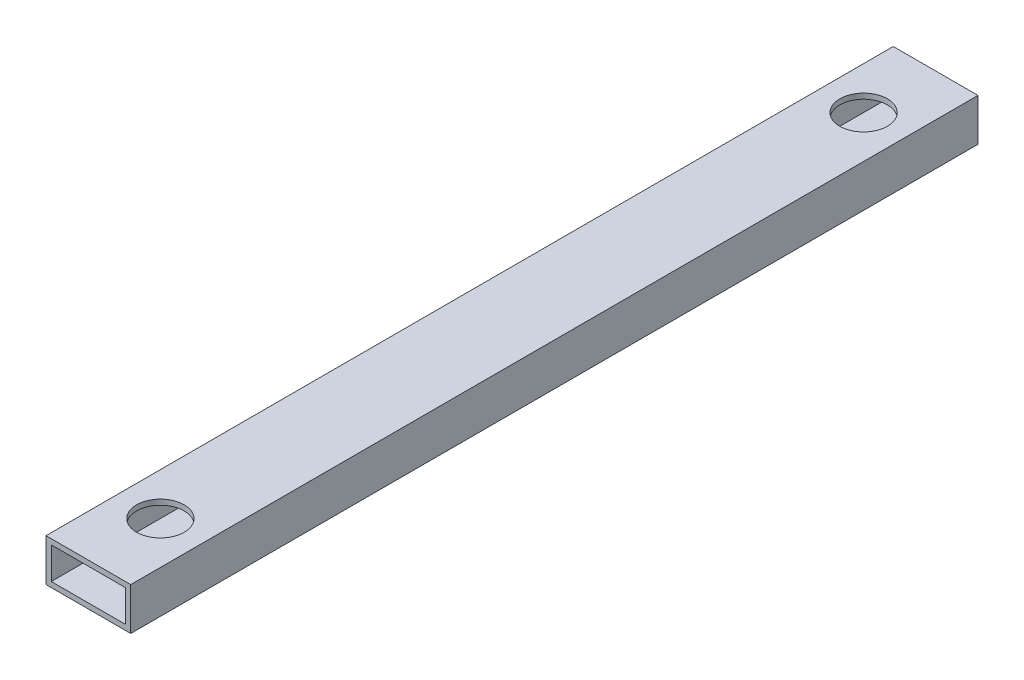
from build123d import *

# Parameters (mm, degrees)
SKETCH1_W           = 50.8
SKETCH1_H           = 25.4
SKETCH1_W_2         = 44.45
SKETCH1_H_2         = 19.05
EXTRUDE_THIN1_DEPTH = 508
SKETCH2_R           = 14.2748
CUT_EXTRUDE1_DEPTH  = 26.4


with BuildPart() as part:
    # Sketch1 → Extrude-Thin1 (new body)
    with BuildSketch(Plane.XY):
        Rectangle(SKETCH1_W, SKETCH1_H)
        Rectangle(SKETCH1_W_2, SKETCH1_H_2, mode=Mode.SUBTRACT)
    extrude(amount=EXTRUDE_THIN1_DEPTH)

    # Sketch2 → Cut-Extrude1 (cut, through all)
    with BuildSketch(Plane(origin=(0, 12.7, 0), x_dir=(1, 0, 0), z_dir=(0, 1, 0))):
        with Locations((0, -464.82)):
            Circle(SKETCH2_R)
        with Locations((0, -43.18)):
            Circle(SKETCH2_R)
    extrude(amount=-CUT_EXTRUDE1_DEPTH, mode=Mode.SUBTRACT)


solid = part.part
